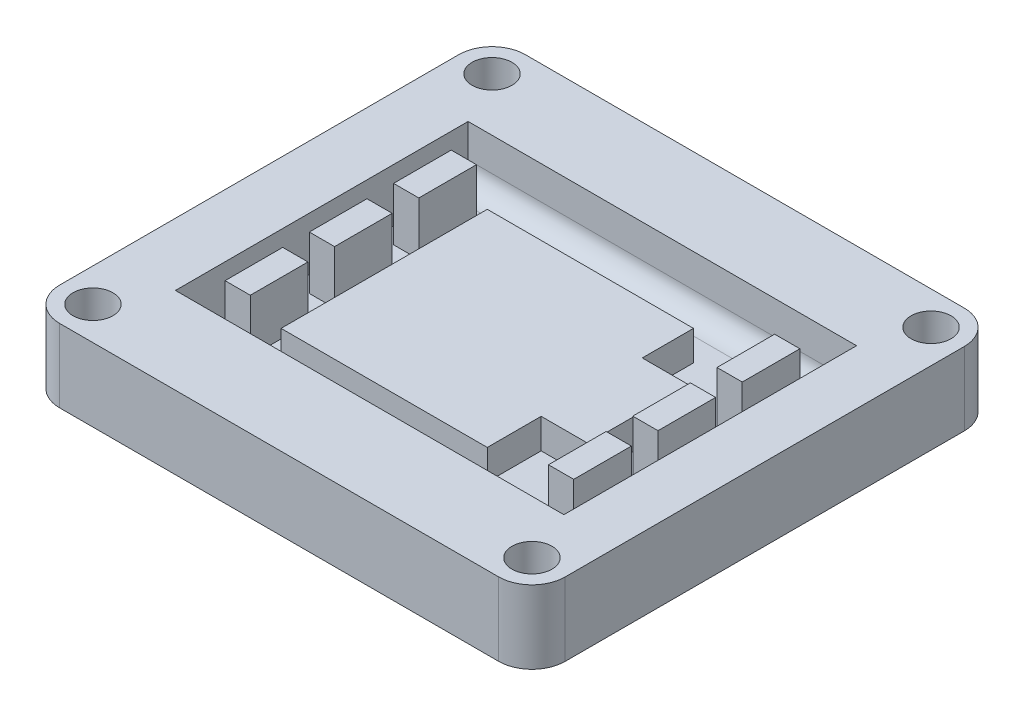
from build123d import *

# Parameters (mm, degrees)
SKETCH2_R                        = 3
BOSS_EXTRUDE1_DEPTH              = 25
SKETCH5_W                        = 200
SKETCH5_H                        = 44
CUT_EXTRUDE1_DEPTH               = 8
SENSORMODULE_BOTTOMMIDDLEE_DEPTH = 4.5
SKETCH12_W                       = 247.875067181
SKETCH12_H                       = 102.432022038
CUT_EXTRUDE2_DEPTH               = 14
SKETCH14_W                       = 9.40210165
SKETCH14_H                       = 8
SKETCH14_W_2                     = 8.199489831
BOSS_EXTRUDE2_DEPTH              = 48
FILLET1_R                        = 3
FILLET2_R                        = 3
SKETCH15_W                       = 3.793616894
SKETCH15_H                       = 8.666666667
SKETCH15_H_2                     = 8.666666666
BOSS_EXTRUDE3_DEPTH              = 8
SKETCH16_W                       = 3.793616895
SKETCH16_H                       = 8.666666667
SKETCH16_H_2                     = 8.666666666
BOSS_EXTRUDE4_DEPTH              = 10


with BuildPart() as part:
    # Sketch2 → Boss-Extrude1 (new body)
    with BuildSketch(Plane(origin=(0, 0, 0), x_dir=(1, 0, 0), z_dir=(0, 1, 0))):
        with BuildLine():
            Line((-33, -35), (33, -35))
            ThreePointArc((33, -35), (36.535533906, -33.535533906), (38, -30))
            Line((38, -30), (38, 30))
            ThreePointArc((38, 30), (36.535533906, 33.535533906), (33, 35))
            Line((33, 35), (-33, 35))
            ThreePointArc((-33, 35), (-36.535533906, 33.535533906), (-38, 30))
            Line((-38, 30), (-38, -30))
            ThreePointArc((-38, -30), (-36.535533906, -33.535533906), (-33, -35))
        make_face()
        with Locations((-33, 30)):
            Circle(SKETCH2_R, mode=Mode.SUBTRACT)
        with Locations((-33, -30)):
            Circle(SKETCH2_R, mode=Mode.SUBTRACT)
        with Locations((33, 30)):
            Circle(SKETCH2_R, mode=Mode.SUBTRACT)
        with Locations((33, -30)):
            Circle(SKETCH2_R, mode=Mode.SUBTRACT)
    extrude(amount=BOSS_EXTRUDE1_DEPTH)

    # Sketch5 → Cut-Extrude1 (cut)
    with BuildSketch(Plane(origin=(0, 25, 0), x_dir=(1, 0, 0), z_dir=(0, 1, 0))):
        Rectangle(SKETCH5_W, SKETCH5_H)
    extrude(amount=-CUT_EXTRUDE1_DEPTH, mode=Mode.SUBTRACT)

    # Sketch6 → SensorModule(bottomMiddlee) (add)
    with BuildSketch(Plane(origin=(87.622938947, 17, 0), x_dir=(1, 0, 0), z_dir=(0, 1, 0))):
        Polygon((-106.839454309, 15.5), (-75.839454309, 15.5), (-75.839454309, 7.8), (-68.839454309, 7.8), (-68.839454309, -7.4), (-75.839454309, -7.4), (-75.839454309, -15.5), (-106.839454309, -15.5), align=None)
    extrude(amount=SENSORMODULE_BOTTOMMIDDLEE_DEPTH)

    # Sketch12 → Cut-Extrude2 (cut)
    with BuildSketch(Plane.XZ):
        with Locations((-0.926975658, -6.36803857)):
            Rectangle(SKETCH12_W, SKETCH12_H)
    extrude(amount=-CUT_EXTRUDE2_DEPTH, mode=Mode.SUBTRACT)

    # Sketch14 → Boss-Extrude2 (add)
    with BuildSketch(Plane.XY.offset(-22)):
        with Locations((-33.298949175, 21)):
            Rectangle(SKETCH14_W, SKETCH14_H)
        with Locations((33.900255085, 21)):
            Rectangle(SKETCH14_W_2, SKETCH14_H)
    extrude(amount=BOSS_EXTRUDE2_DEPTH)

    # Fillet1
    fillet1_edges = [part.edges().sort_by_distance(p)[0] for p in [
        (0.601305909, 17, -22),
    ]]
    fillet(fillet1_edges, radius=FILLET1_R)

    # Fillet2
    fillet2_edges = [part.edges().sort_by_distance(p)[0] for p in [
        (0.601305909, 17, 22),
    ]]
    fillet(fillet2_edges, radius=FILLET2_R)

    # Sketch15 → Boss-Extrude3 (add)
    with BuildSketch(Plane(origin=(3.489394794, 17, 0), x_dir=(1, 0, 0), z_dir=(0, 1, 0))):
        with Locations((-27.729371665, 12.666666666)):
            Rectangle(SKETCH15_W, SKETCH15_H)
        with Locations((-27.729371665, 0)):
            Rectangle(SKETCH15_W, SKETCH15_H_2)
        with Locations((-27.729371665, -12.666666666)):
            Rectangle(SKETCH15_W, SKETCH15_H)
    extrude(amount=BOSS_EXTRUDE3_DEPTH)

    # Sketch16 → Boss-Extrude4 (add)
    with BuildSketch(Plane(origin=(51.94610351, 25, 9.710186869), x_dir=(1, 0, 0), z_dir=(0, 1, 0))):
        with Locations((-27.906397887, 22.722574296)):
            Rectangle(SKETCH16_W, SKETCH16_H)
        with Locations((-27.906397887, 10.055907629)):
            Rectangle(SKETCH16_W, SKETCH16_H_2)
        with Locations((-27.906397887, -2.610759038)):
            Rectangle(SKETCH16_W, SKETCH16_H)
    extrude(amount=-BOSS_EXTRUDE4_DEPTH)


solid = part.part
